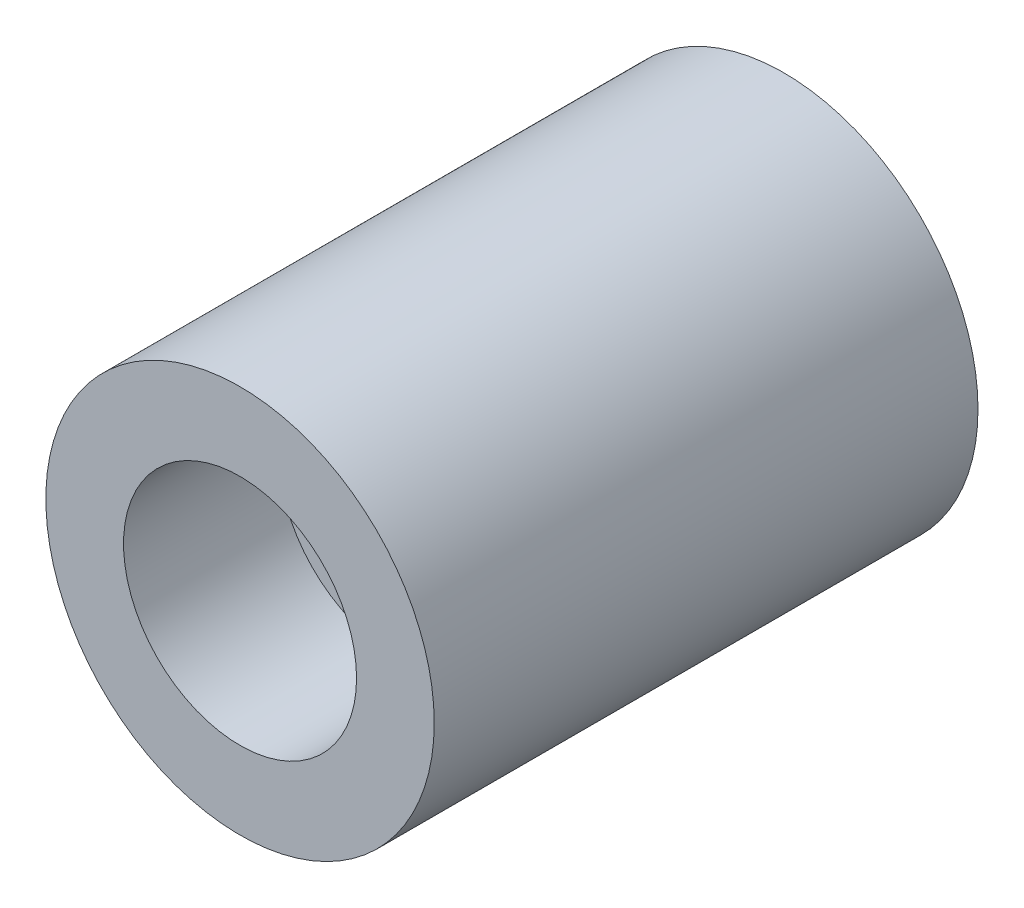
from build123d import *

# Parameters (mm, degrees)
SKETCH1_R           = 50
BOSS_EXTRUDE1_DEPTH = 140
SKETCH2_R           = 30
CUT_EXTRUDE1_DEPTH  = 40
SKETCH3_R           = 10
CUT_EXTRUDE2_DEPTH  = 80


with BuildPart() as part:
    # Sketch1 → Boss-Extrude1 (new body)
    with BuildSketch(Plane.XY):
        Circle(SKETCH1_R)
    extrude(amount=BOSS_EXTRUDE1_DEPTH)

    # Sketch2 → Cut-Extrude1 (cut)
    with BuildSketch(Plane.XY.offset(140)):
        Circle(SKETCH2_R)
    extrude(amount=-CUT_EXTRUDE1_DEPTH, mode=Mode.SUBTRACT)

    # Sketch3 → Cut-Extrude2 (cut)
    with BuildSketch(Plane.XY.offset(100)):
        Circle(SKETCH3_R)
    extrude(amount=-CUT_EXTRUDE2_DEPTH, mode=Mode.SUBTRACT)


solid = part.part
